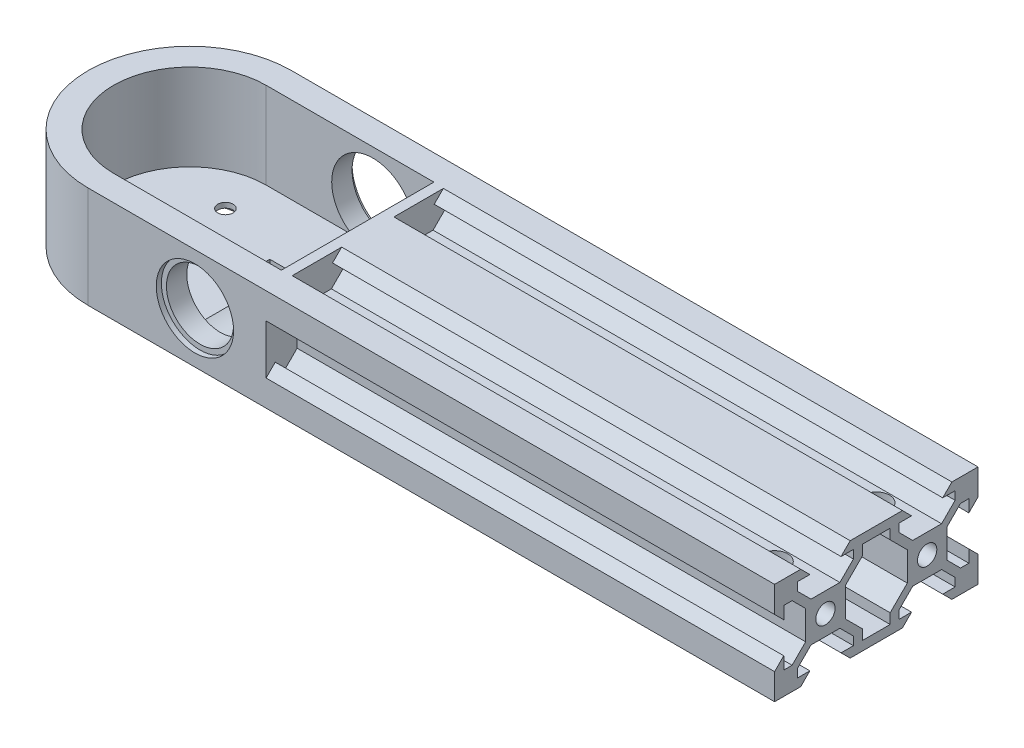
from build123d import *

# Parameters (mm, degrees)
SKETCH1_W           = 95
SKETCH1_H           = 40
BOSS_EXTRUDE1_DEPTH = 20
BOSS_EXTRUDE3_DEPTH = 3
BOSS_EXTRUDE2_DEPTH = 20
SKETCH7_R           = 1.9
CUT_EXTRUDE5_DEPTH  = 100
BOSS_EXTRUDE4_DEPTH = 2
SKETCH10_R          = 10.5
CUT_EXTRUDE6_DEPTH  = 2
CUT_EXTRUDE7_REACH  = 20
SKETCH12_R          = 2
SKETCH12_R_2        = 1.5
SKETCH13_R          = 7.6
CUT_EXTRUDE9_DEPTH  = 1
CUT_EXTRUDE10_REACH = 41
SKETCH15_R          = 6.6
SKETCH16_R          = 2.6
CUT_EXTRUDE11_DEPTH = 14.9
SKETCH18_R          = 9.1
CUT_EXTRUDE12_DEPTH = 1
SKETCH19_R          = 8.1
CUT_EXTRUDE15_DEPTH = 34
SKETCH20_W          = 5.46
SKETCH20_H          = 1.201320344
CUT_EXTRUDE16_DEPTH = 22


with BuildPart() as part:
    # Sketch1 → Boss-Extrude1 (new body)
    with BuildSketch(Plane(origin=(0, 0, 0), x_dir=(1, 0, 0), z_dir=(0, 1, 0))):
        Rectangle(SKETCH1_W, SKETCH1_H)
    extrude(amount=BOSS_EXTRUDE1_DEPTH)

    # Sketch8 → Boss-Extrude2 (add)
    with BuildSketch(Plane(origin=(0, 0, 0), x_dir=(-1, 0, 0), z_dir=(0, -1, 0))):
        with BuildLine():
            Line((47.5, -20), (87.5, -20))
            ThreePointArc((87.5, -20), (107.5, 0), (87.5, 20))
            Line((87.5, 20), (47.5, 20))
            Line((47.5, 20), (47.5, -20))
        make_face()
        with BuildLine():
            Line((52.5, -15), (87.5, -15))
            ThreePointArc((87.5, -15), (102.5, 0), (87.5, 15))
            Line((87.5, 15), (52.5, 15))
            Line((52.5, 15), (52.5, -15))
        make_face(mode=Mode.SUBTRACT)
    extrude(amount=-BOSS_EXTRUDE2_DEPTH)

    # Sketch7 → Cut-Extrude5 (cut)
    with BuildSketch(Plane(origin=(47.5, 0, 0), x_dir=(0, 0, -1), z_dir=(1, 0, 0))):
        Polygon((-18.2, 13.064339828), (-20, 14.864339828), (-20, 5.134339828), (-18.2, 6.934339828), (-18.2, 4.499339828), (-16.56, 4.499339828), (-13.9, 7.159339828), (-13.9, 12.839339828), (-16.56, 15.499339828), (-18.2, 15.499339828), align=None)
        Polygon((-12.839339828, 13.9), (-7.159339828, 13.9), (-4.499339828, 16.56), (-4.499339828, 18.2), (-6.934339828, 18.2), (-5.134339828, 20), (-14.864339828, 20), (-13.064339828, 18.2), (-15.499339828, 18.2), (-15.499339828, 16.56), align=None)
        Polygon((-13.064339828, 1.798679656), (-14.863019485, 0), (-5.135660172, 0), (-6.934339828, 1.798679656), (-4.499339828, 1.798679656), (-4.499339828, 3.438679656), (-7.159339828, 6.098679656), (-12.839339828, 6.098679656), (-15.499339828, 3.438679656), (-15.499339828, 1.798679656), align=None)
        Polygon((14.864339828, 20), (5.134339828, 20), (6.934339828, 18.2), (4.499339828, 18.2), (4.499339828, 16.56), (7.159339828, 13.9), (12.839339828, 13.9), (15.499339828, 16.56), (15.499339828, 18.2), (13.064339828, 18.2), align=None)
        Polygon((5.135660172, 0), (14.863019485, 0), (13.064339828, 1.798679656), (15.499339828, 1.798679656), (15.499339828, 3.438679656), (12.839339828, 6.098679656), (7.159339828, 6.098679656), (4.499339828, 3.438679656), (4.499339828, 1.798679656), (6.934339828, 1.798679656), align=None)
        Polygon((20, 5.134339828), (20, 14.864339828), (18.2, 13.064339828), (18.2, 15.499339828), (16.56, 15.499339828), (13.9, 12.839339828), (13.9, 7.159339828), (16.56, 4.499339828), (18.2, 4.499339828), (18.2, 6.934339828), align=None)
        Polygon((6.098679656, 12.839339828), (6.098679656, 7.159339828), (2.73, 3.790660172), (2.73, 1.798679656), (-2.73, 1.798679656), (-2.73, 3.790660172), (-6.098679656, 7.159339828), (-6.098679656, 12.839339828), (-2.73, 16.208019485), (-2.73, 18.2), (2.73, 18.2), (2.73, 16.208019485), align=None)
        with Locations((-10, 10)):
            Circle(SKETCH7_R)
        with Locations((10, 10)):
            Circle(SKETCH7_R)
    extrude(amount=-CUT_EXTRUDE5_DEPTH, mode=Mode.SUBTRACT)



with BuildPart() as body_2:
    # Sketch8_3 → Boss-Extrude3 (new body)
    with BuildSketch(Plane(origin=(0, 0, 0), x_dir=(-1, 0, 0), z_dir=(0, -1, 0))):
        with BuildLine():
            Line((52.5, -15), (87.5, -15))
            ThreePointArc((87.5, -15), (102.5, 0), (87.5, 15))
            Line((87.5, 15), (52.5, 15))
            Line((52.5, 15), (52.5, -15))
        make_face()
    extrude(amount=-BOSS_EXTRUDE3_DEPTH)


with BuildPart() as part_1:
    add(part.part)

    add(body_2.part)  # Boss-Extrude4 merges body 2
    # Sketch9 → Boss-Extrude4 (add)
    with BuildSketch(Plane.ZY.offset(52.5)):
        Polygon((-15, 20), (-2.73, 20), (2.73, 20), (15, 20), (15, 3), (2.73, 3), (2.73, 3.790660172), (6.098679656, 7.159339828), (6.098679656, 12.839339828), (2.73, 16.208019485), (2.73, 18.2), (-2.73, 18.2), (-2.73, 16.208019485), (-6.098679656, 12.839339828), (-6.098679656, 7.159339828), (-2.73, 3.790660172), (-2.73, 3), (-15, 3), align=None)
    extrude(amount=BOSS_EXTRUDE4_DEPTH)

    # Sketch10 → Cut-Extrude6 (cut)
    with BuildSketch(Plane(origin=(0, 0, 0), x_dir=(-1, 0, 0), z_dir=(0, -1, 0))):
        with Locations((87.5, 0)):
            Circle(SKETCH10_R)
    extrude(amount=-CUT_EXTRUDE6_DEPTH, mode=Mode.SUBTRACT)

    # Sketch12 → Cut-Extrude7 (cut, up to next)
    with BuildSketch(Plane(origin=(0, 2, 0), x_dir=(-1, 0, 0), z_dir=(0, -1, 0)), mode=Mode.PRIVATE) as cut_extrude7_sk1:
        with Locations((87.5, 0)):
            Circle(SKETCH12_R)
    cut_extrude7_tool1 = extrude(cut_extrude7_sk1.sketch, amount=-CUT_EXTRUDE7_REACH, mode=Mode.PRIVATE) & part_1.part
    add(cut_extrude7_tool1.solids().sort_by_distance((-87.5, 2, 0))[0], mode=Mode.SUBTRACT)
    # Sketch12 → Cut-Extrude7 (cut, up to next)
    with BuildSketch(Plane(origin=(0, 2, 0), x_dir=(-1, 0, 0), z_dir=(0, -1, 0)), mode=Mode.PRIVATE) as cut_extrude7_sk2:
        with Locations((87.5, -7)):
            Circle(SKETCH12_R_2)
    cut_extrude7_tool2 = extrude(cut_extrude7_sk2.sketch, amount=-CUT_EXTRUDE7_REACH, mode=Mode.PRIVATE) & part_1.part
    add(cut_extrude7_tool2.solids().sort_by_distance((-87.5, 2, 7))[0], mode=Mode.SUBTRACT)
    # Sketch12 → Cut-Extrude7 (cut, up to next)
    with BuildSketch(Plane(origin=(0, 2, 0), x_dir=(-1, 0, 0), z_dir=(0, -1, 0)), mode=Mode.PRIVATE) as cut_extrude7_sk3:
        with Locations((80.5, 0)):
            Circle(SKETCH12_R_2)
    cut_extrude7_tool3 = extrude(cut_extrude7_sk3.sketch, amount=-CUT_EXTRUDE7_REACH, mode=Mode.PRIVATE) & part_1.part
    add(cut_extrude7_tool3.solids().sort_by_distance((-80.5, 2, 0))[0], mode=Mode.SUBTRACT)
    # Sketch12 → Cut-Extrude7 (cut, up to next)
    with BuildSketch(Plane(origin=(0, 2, 0), x_dir=(-1, 0, 0), z_dir=(0, -1, 0)), mode=Mode.PRIVATE) as cut_extrude7_sk4:
        with Locations((87.5, 7)):
            Circle(SKETCH12_R_2)
    cut_extrude7_tool4 = extrude(cut_extrude7_sk4.sketch, amount=-CUT_EXTRUDE7_REACH, mode=Mode.PRIVATE) & part_1.part
    add(cut_extrude7_tool4.solids().sort_by_distance((-87.5, 2, -7))[0], mode=Mode.SUBTRACT)
    # Sketch12 → Cut-Extrude7 (cut, up to next)
    with BuildSketch(Plane(origin=(0, 2, 0), x_dir=(-1, 0, 0), z_dir=(0, -1, 0)), mode=Mode.PRIVATE) as cut_extrude7_sk5:
        with Locations((94.5, 0)):
            Circle(SKETCH12_R_2)
    cut_extrude7_tool5 = extrude(cut_extrude7_sk5.sketch, amount=-CUT_EXTRUDE7_REACH, mode=Mode.PRIVATE) & part_1.part
    add(cut_extrude7_tool5.solids().sort_by_distance((-94.5, 2, 0))[0], mode=Mode.SUBTRACT)

    # Sketch13 → Cut-Extrude9 (cut)
    with BuildSketch(Plane.XY.offset(20)):
        with Locations((-66.5, 9.999339828)):
            Circle(SKETCH13_R)
    extrude(amount=-CUT_EXTRUDE9_DEPTH, mode=Mode.SUBTRACT)

    # Sketch15 → Cut-Extrude10 (cut, up to next)
    with BuildSketch(Plane.XY.offset(19), mode=Mode.PRIVATE) as cut_extrude10_sk1:
        with Locations((-66.5, 9.999339828)):
            Circle(SKETCH15_R)
    cut_extrude10_tool1 = extrude(cut_extrude10_sk1.sketch, amount=-CUT_EXTRUDE10_REACH, mode=Mode.PRIVATE) & part_1.part
    add(cut_extrude10_tool1.solids().sort_by_distance((-66.5, 9.99934, 19))[0], mode=Mode.SUBTRACT)

    # Sketch16 → Cut-Extrude11 (cut, through all)
    with BuildSketch(Plane(origin=(0, 13.9, 0), x_dir=(1, 0, 0), z_dir=(0, 1, 0))):
        with Locations((37.5, -9.999339828)):
            Circle(SKETCH16_R)
        with Locations((37.5, 9.999339828)):
            Circle(SKETCH16_R)
    extrude(amount=-CUT_EXTRUDE11_DEPTH, mode=Mode.SUBTRACT)

    # Sketch18 → Cut-Extrude12 (cut)
    with BuildSketch(Plane(origin=(0, 0, -20), x_dir=(-1, 0, 0), z_dir=(0, 0, -1))):
        with Locations((66.5, 9.999339828)):
            Circle(SKETCH18_R)
    extrude(amount=-CUT_EXTRUDE12_DEPTH, mode=Mode.SUBTRACT)

    # Sketch19 → Cut-Extrude15 (cut)
    with BuildSketch(Plane(origin=(0, 0, -19), x_dir=(-1, 0, 0), z_dir=(0, 0, -1))):
        with Locations((66.5, 9.999339828)):
            Circle(SKETCH19_R)
    extrude(amount=-CUT_EXTRUDE15_DEPTH, mode=Mode.SUBTRACT)

    # Sketch20 → Cut-Extrude16 (cut)
    with BuildSketch(Plane(origin=(-52.5, 0, 0), x_dir=(0, 0, -1), z_dir=(1, 0, 0))):
        with Locations((0, 2.399339828)):
            Rectangle(SKETCH20_W, SKETCH20_H)
    extrude(amount=-CUT_EXTRUDE16_DEPTH, mode=Mode.SUBTRACT)


solid = part_1.part
